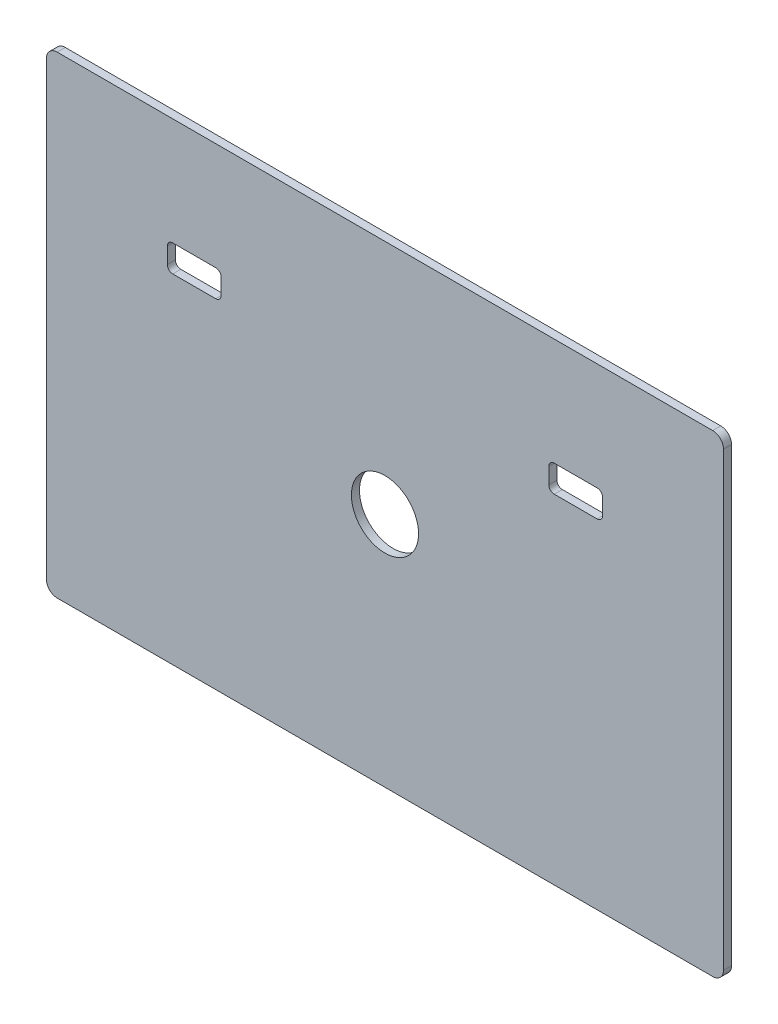
from build123d import *

# Parameters (mm, degrees)
SKETCH1_W           = 252
SKETCH1_H           = 176
BOSS_EXTRUDE1_DEPTH = 3
SKETCH2_R           = 12.5
SKETCH2_W           = 20
SKETCH2_H           = 10
CUT_EXTRUDE1_DEPTH  = 4
FILLET2_R           = 2
FILLET3_R           = 4


with BuildPart() as part:
    # Sketch1 → Boss-Extrude1 (new body)
    with BuildSketch(Plane.XY):
        Rectangle(SKETCH1_W, SKETCH1_H)
    extrude(amount=BOSS_EXTRUDE1_DEPTH)

    # Sketch2 → Cut-Extrude1 (cut, through all)
    with BuildSketch(Plane.XY.offset(3)):
        Circle(SKETCH2_R)
        with Locations((-71, 43)):
            Rectangle(SKETCH2_W, SKETCH2_H)
        with Locations((71, 43)):
            Rectangle(SKETCH2_W, SKETCH2_H)
    extrude(amount=-CUT_EXTRUDE1_DEPTH, mode=Mode.SUBTRACT)

    # Fillet2
    fillet2_edges = [part.edges().sort_by_distance(p)[0] for p in [
        (-81, 38, 1.5),
        (-81, 48, 1.5),
        (-61, 48, 1.5),
        (-61, 38, 1.5),
        (81, 48, 1.5),
        (81, 38, 1.5),
        (61, 38, 1.5),
        (61, 48, 1.5),
    ]]
    fillet(fillet2_edges, radius=FILLET2_R)

    # Fillet3
    fillet3_edges = [part.edges().sort_by_distance(p)[0] for p in [
        (126, -88, 1.5),
        (-126, -88, 1.5),
        (-126, 88, 1.5),
        (126, 88, 1.5),
    ]]
    fillet(fillet3_edges, radius=FILLET3_R)


solid = part.part
